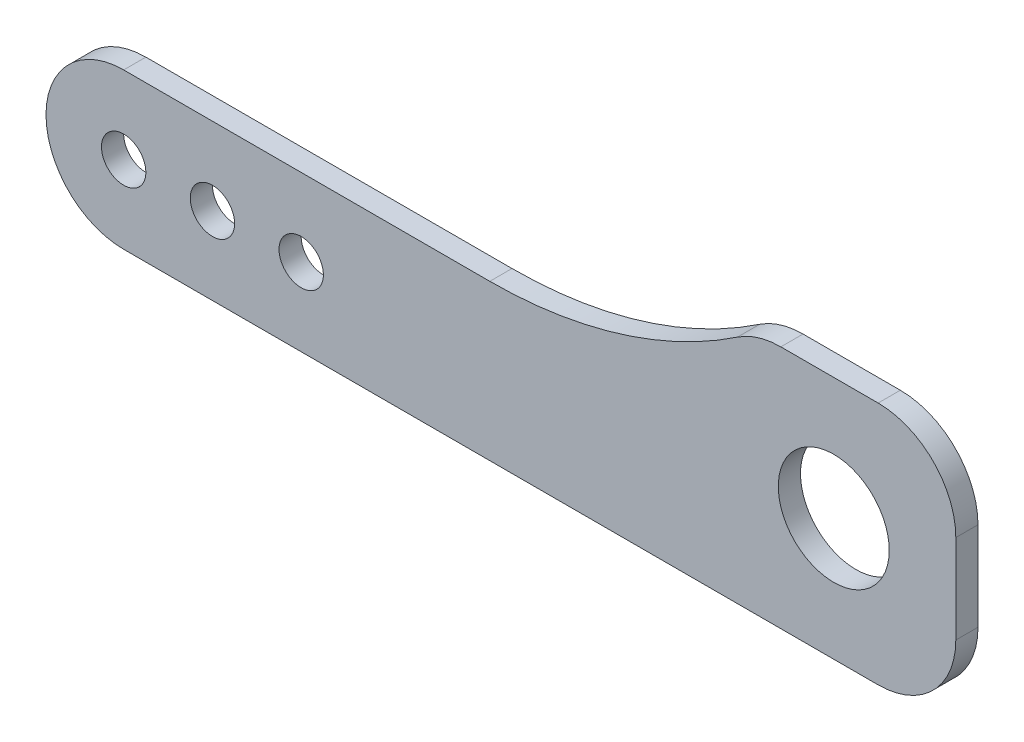
from build123d import *

# Parameters (mm, degrees)
BOSS_EXTRUDE1_DEPTH = 2
SKETCH2_R           = 2
CUT_EXTRUDE1_DEPTH  = 2
SKETCH3_R           = 5
CUT_EXTRUDE2_DEPTH  = 2


with BuildPart() as part:
    # Sketch1 → Boss-Extrude1 (new body)
    with BuildSketch(Plane.XY):
        with BuildLine():
            Line((0, 7), (33, 7))
            ThreePointArc((33, 7), (44.66919932, 8.739971416), (55.323194976, 13.808510638))
            ThreePointArc((55.323194976, 13.808510638), (57.187644216, 14.695505002), (59.229754097, 15))
            Line((59.229754097, 15), (68, 15))
            ThreePointArc((68, 15), (72.949747468, 12.949747468), (75, 8))
            Line((75, 8), (75, 0))
            ThreePointArc((75, 0), (72.949747468, -4.949747468), (68, -7))
            Line((68, -7), (0, -7))
            ThreePointArc((0, -7), (-7, 0), (0, 7))
        make_face()
    extrude(amount=BOSS_EXTRUDE1_DEPTH)

    # Sketch2 → Cut-Extrude1 (cut)
    with BuildSketch(Plane.XY.offset(2)):
        Circle(SKETCH2_R)
        with Locations((8, 0)):
            Circle(SKETCH2_R)
        with Locations((16, 0)):
            Circle(SKETCH2_R)
    extrude(amount=-CUT_EXTRUDE1_DEPTH, mode=Mode.SUBTRACT)

    # Sketch3 → Cut-Extrude2 (cut)
    with BuildSketch(Plane.XY.offset(2)):
        with Locations((64, 4)):
            Circle(SKETCH3_R)
    extrude(amount=-CUT_EXTRUDE2_DEPTH, mode=Mode.SUBTRACT)


solid = part.part
